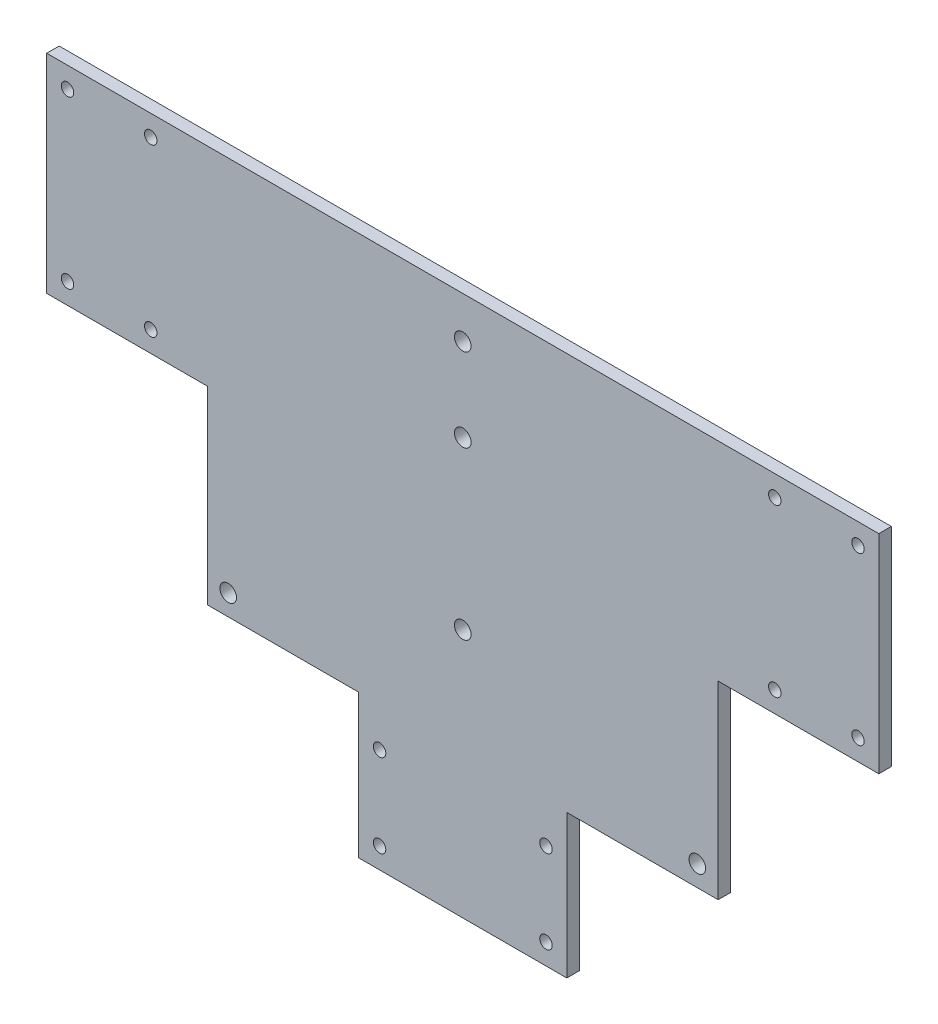
from build123d import *

# Parameters (mm, degrees)
ESQUISSE1_R        = 2
ESQUISSE1_R_2      = 1.5
BOSS_EXTRU_1_DEPTH = 3


with BuildPart() as part:
    # Esquisse1 → Boss.-Extru.1 (new body)
    with BuildSketch(Plane.XY):
        Polygon((0, 50), (-100, 50), (-100, 0), (-61.381557247, 0), (-61.381557247, -45.5212086), (-25, -45.5212086), (-25, -80), (25, -80), (25, -45.5212086), (61.381557247, -45.5212086), (61.381557247, 0), (100, 0), (100, 50), align=None)
        with Locations((0, 20)):
            Circle(ESQUISSE1_R, mode=Mode.SUBTRACT)
        with Locations((0, -20)):
            Circle(ESQUISSE1_R, mode=Mode.SUBTRACT)
        with Locations((0, 40)):
            Circle(ESQUISSE1_R, mode=Mode.SUBTRACT)
        with Locations((-20, -55)):
            Circle(ESQUISSE1_R_2, mode=Mode.SUBTRACT)
        with Locations((20, -55)):
            Circle(ESQUISSE1_R_2, mode=Mode.SUBTRACT)
        with Locations((20, -75)):
            Circle(ESQUISSE1_R_2, mode=Mode.SUBTRACT)
        with Locations((-20, -75)):
            Circle(ESQUISSE1_R_2, mode=Mode.SUBTRACT)
        with Locations((-95, 45)):
            Circle(ESQUISSE1_R_2, mode=Mode.SUBTRACT)
        with Locations((-75, 45)):
            Circle(ESQUISSE1_R_2, mode=Mode.SUBTRACT)
        with Locations((-75, 5)):
            Circle(ESQUISSE1_R_2, mode=Mode.SUBTRACT)
        with Locations((-95, 5)):
            Circle(ESQUISSE1_R_2, mode=Mode.SUBTRACT)
        with Locations((75, 5)):
            Circle(ESQUISSE1_R_2, mode=Mode.SUBTRACT)
        with Locations((95, 5)):
            Circle(ESQUISSE1_R_2, mode=Mode.SUBTRACT)
        with Locations((75, 45)):
            Circle(ESQUISSE1_R_2, mode=Mode.SUBTRACT)
        with Locations((95, 45)):
            Circle(ESQUISSE1_R_2, mode=Mode.SUBTRACT)
        with Locations((56.381557247, -40.5212086)):
            Circle(ESQUISSE1_R, mode=Mode.SUBTRACT)
        with Locations((-56.381557247, -40.5212086)):
            Circle(ESQUISSE1_R, mode=Mode.SUBTRACT)
    extrude(amount=BOSS_EXTRU_1_DEPTH)


solid = part.part
